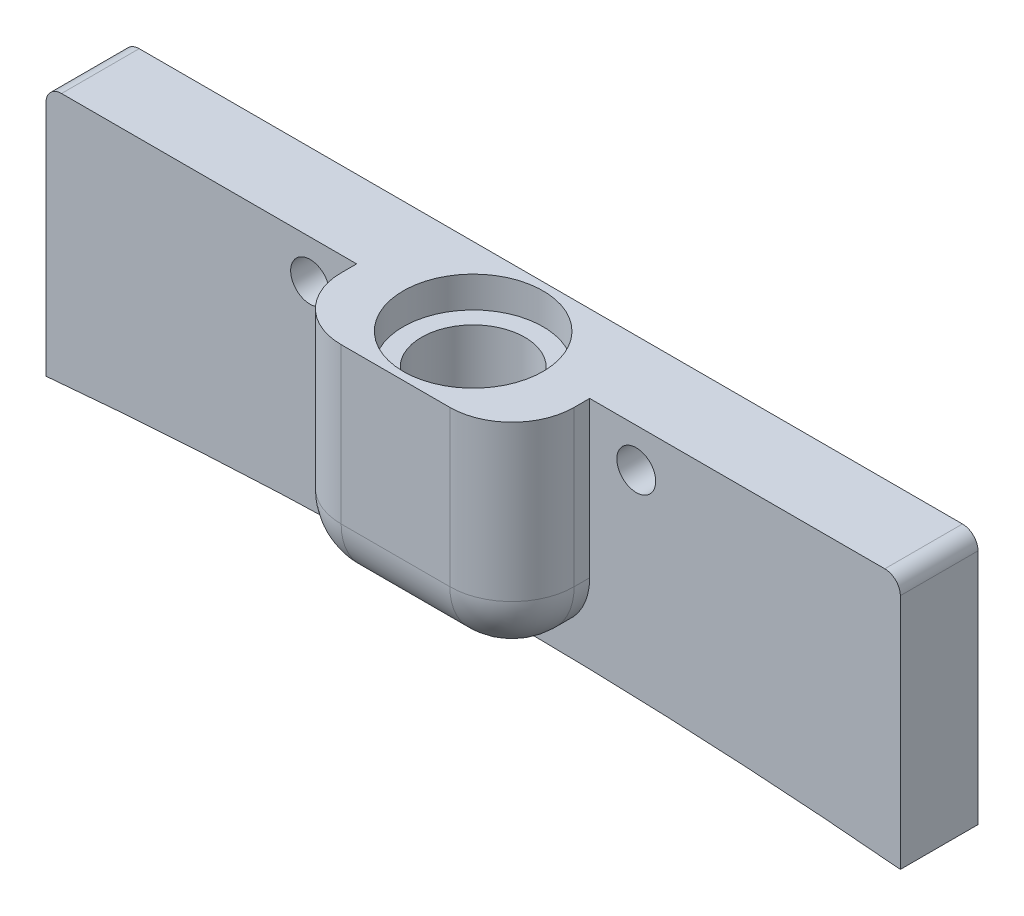
from build123d import *

# Parameters (mm, degrees)
BOSS_EXTRUDE1_DEPTH                     = 5
SKETCH4_W                               = 15
SKETCH4_H                               = 14
BOSS_EXTRUDE2_DEPTH                     = 5
CBORE_FOR_M6_HEX_HEAD_BOLT1_D           = 6.647
CBORE_FOR_M6_HEX_HEAD_BOLT1_DEPTH       = 10
CBORE_FOR_M6_HEX_HEAD_BOLT1_CBORE_D     = 9
CBORE_FOR_M6_HEX_HEAD_BOLT1_CBORE_DEPTH = 2
CBORE_FOR_M6_HEX_HEAD_BOLT1_TIP         = 1.996960267
FILLET1_R                               = 1
FILLET2_R                               = 4
TAP_DRILL_FOR_M3X0_5_TAP1_D             = 2.5


with BuildPart() as part:
    # Sketch1 → Boss-Extrude1 (new body)
    with BuildSketch(Plane(origin=(0, 0, 0), x_dir=(-1, 0, 0), z_dir=(0, 0, -1))):
        with BuildLine():
            Line((27.500000074, -16.263075607), (27.500000074, 0))
            Line((27.500000074, 0), (-27.5, 0))
            Line((-27.5, 0), (-27.5, -16.2630756))
            ThreePointArc((-27.5, -16.2630756), (3.7e-08, -15), (27.500000074, -16.263075607))
        make_face()
    extrude(amount=-BOSS_EXTRUDE1_DEPTH)

    # Sketch4 → Boss-Extrude2 (add)
    with BuildSketch(Plane.XY.offset(5)):
        with Locations((0, -7)):
            Rectangle(SKETCH4_W, SKETCH4_H)
    extrude(amount=BOSS_EXTRUDE2_DEPTH)

    # CBORE for M6 Hex Head Bolt1
    with Locations(Plane(origin=(0, 0, 0), x_dir=(1, 0, 0), z_dir=(0, 1, 0))):
        with Locations((0, -5)):
            CounterBoreHole(CBORE_FOR_M6_HEX_HEAD_BOLT1_D / 2, CBORE_FOR_M6_HEX_HEAD_BOLT1_CBORE_D / 2, CBORE_FOR_M6_HEX_HEAD_BOLT1_CBORE_DEPTH, depth=CBORE_FOR_M6_HEX_HEAD_BOLT1_DEPTH)
            with Locations((0, 0, -(CBORE_FOR_M6_HEX_HEAD_BOLT1_DEPTH + CBORE_FOR_M6_HEX_HEAD_BOLT1_TIP / 2))):  # 118° drill point
                Cone(0, CBORE_FOR_M6_HEX_HEAD_BOLT1_D / 2, CBORE_FOR_M6_HEX_HEAD_BOLT1_TIP, mode=Mode.SUBTRACT)

    # Fillet1
    fillet1_edges = [part.edges().sort_by_distance(p)[0] for p in [
        (27.5, 0, 2.5),
        (-27.500000074, 0, 2.5),
    ]]
    fillet(fillet1_edges, radius=FILLET1_R)

    # Fillet2
    fillet2_edges = [part.edges().sort_by_distance(p)[0] for p in [
        (7.5, -14, 7.5),
        (7.5, -7, 10),
        (-7.5, -14, 7.5),
        (0, -14, 10),
        (-7.5, -7, 10),
    ]]
    fillet(fillet2_edges, radius=FILLET2_R)

    # Tap Drill for M3x0.5 Tap1 (through all)
    with Locations(Plane(origin=(-10.5, -2.5, 5), x_dir=(1, 0, 0), z_dir=(0, 0, 1))):
        with Locations((0, 0), (21, 0)):
            Hole(TAP_DRILL_FOR_M3X0_5_TAP1_D / 2)


solid = part.part
